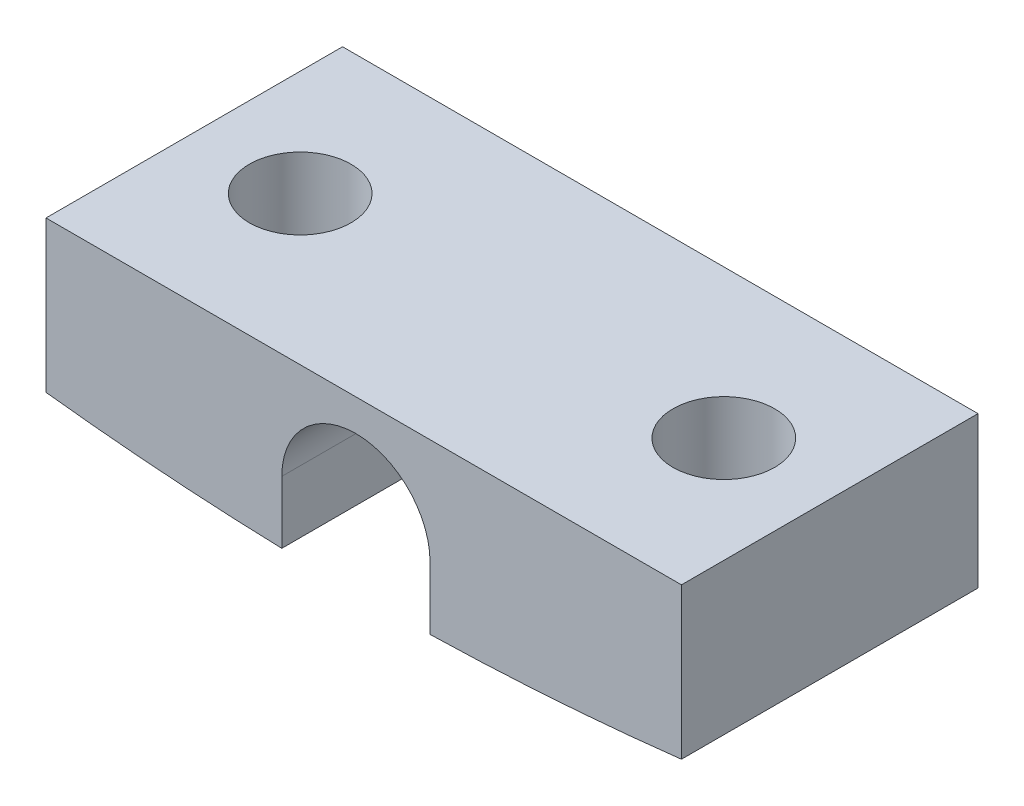
from build123d import *

# Parameters (mm, degrees)
BOSS_EXTRUDE1_DEPTH = 7
SKETCH2_R           = 1.2
CUT_EXTRUDE1_DEPTH  = 10


with BuildPart() as part:
    # Sketch1 → Boss-Extrude1 (new body)
    with BuildSketch(Plane.XY):
        with BuildLine():
            Line((0, 0), (15, 0))
            Line((15, 0), (15, -3.565857851))
            ThreePointArc((15, -3.565857851), (12.037715119, -3.841415326), (9.065924059, -3.981134815))
            Line((9.065924059, -3.981134815), (9.065924059, -2.5))
            ThreePointArc((9.065924059, -2.5), (7.315924059, -0.75), (5.565924059, -2.5))
            Line((5.565924059, -2.5), (5.565924059, -3.971219399))
            ThreePointArc((5.565924059, -3.971219399), (2.778609663, -3.828299941), (0, -3.565857851))
            Line((0, -3.565857851), (0, 0))
        make_face()
    extrude(amount=BOSS_EXTRUDE1_DEPTH)

    # Sketch2 → Cut-Extrude1 (cut)
    with BuildSketch(Plane(origin=(0, 0, 0), x_dir=(1, 0, 0), z_dir=(0, 1, 0))):
        with Locations((12.5, -3.5)):
            Circle(SKETCH2_R)
        with Locations((2.5, -3.5)):
            Circle(SKETCH2_R)
    extrude(amount=-CUT_EXTRUDE1_DEPTH, mode=Mode.SUBTRACT)


solid = part.part
